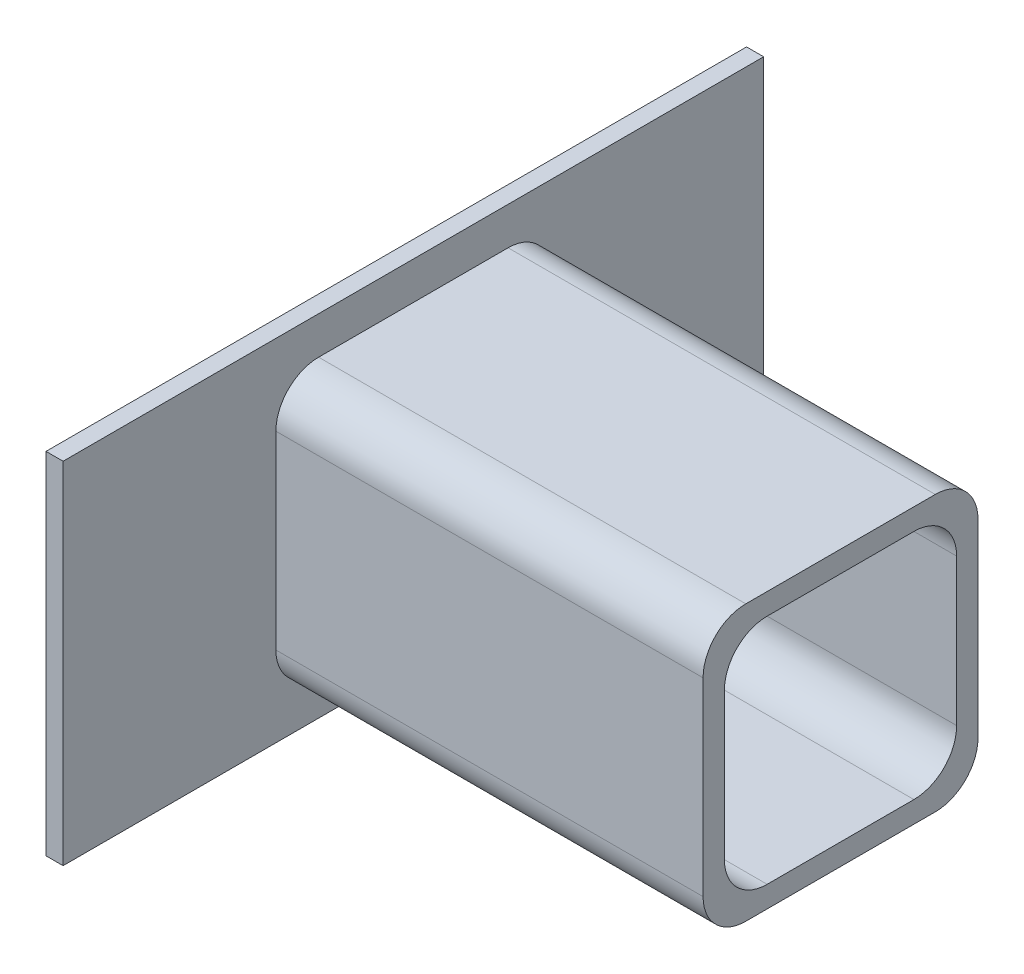
from build123d import *

# Parameters (mm, degrees)
SKETCH1_W           = 164
SKETCH1_H           = 82
BOSS_EXTRUDE1_DEPTH = 4
BOSS_EXTRUDE5_DEPTH = 100


with BuildPart() as part:
    # Sketch1 → Boss-Extrude1 (new body)
    with BuildSketch(Plane(origin=(0, 0, 0), x_dir=(0, 0, -1), z_dir=(1, 0, 0))):
        Rectangle(SKETCH1_W, SKETCH1_H)
    extrude(amount=BOSS_EXTRUDE1_DEPTH)

    # Sketch7 → Boss-Extrude5 (add)
    with BuildSketch(Plane(origin=(4, 0, 0), x_dir=(0, 0, -1), z_dir=(1, 0, 0))):
        with BuildLine():
            Line((-22.18, -32.18), (22.18, -32.18))
            ThreePointArc((22.18, -32.18), (29.251067812, -29.251067812), (32.18, -22.18))
            Line((32.18, -22.18), (32.18, 22.18))
            ThreePointArc((32.18, 22.18), (29.251067812, 29.251067812), (22.18, 32.18))
            Line((22.18, 32.18), (-22.18, 32.18))
            ThreePointArc((-22.18, 32.18), (-29.251067812, 29.251067812), (-32.18, 22.18))
            Line((-32.18, 22.18), (-32.18, -22.18))
            ThreePointArc((-32.18, -22.18), (-29.251067812, -29.251067812), (-22.18, -32.18))
        make_face()
        with BuildLine():
            Line((-17.18, -27.18), (17.18, -27.18))
            ThreePointArc((17.18, -27.18), (24.251067812, -24.251067812), (27.18, -17.18))
            Line((27.18, -17.18), (27.18, 17.18))
            ThreePointArc((27.18, 17.18), (24.251067812, 24.251067812), (17.18, 27.18))
            Line((17.18, 27.18), (-17.18, 27.18))
            ThreePointArc((-17.18, 27.18), (-24.251067812, 24.251067812), (-27.18, 17.18))
            Line((-27.18, 17.18), (-27.18, -17.18))
            ThreePointArc((-27.18, -17.18), (-24.251067812, -24.251067812), (-17.18, -27.18))
        make_face(mode=Mode.SUBTRACT)
    extrude(amount=BOSS_EXTRUDE5_DEPTH)


solid = part.part
